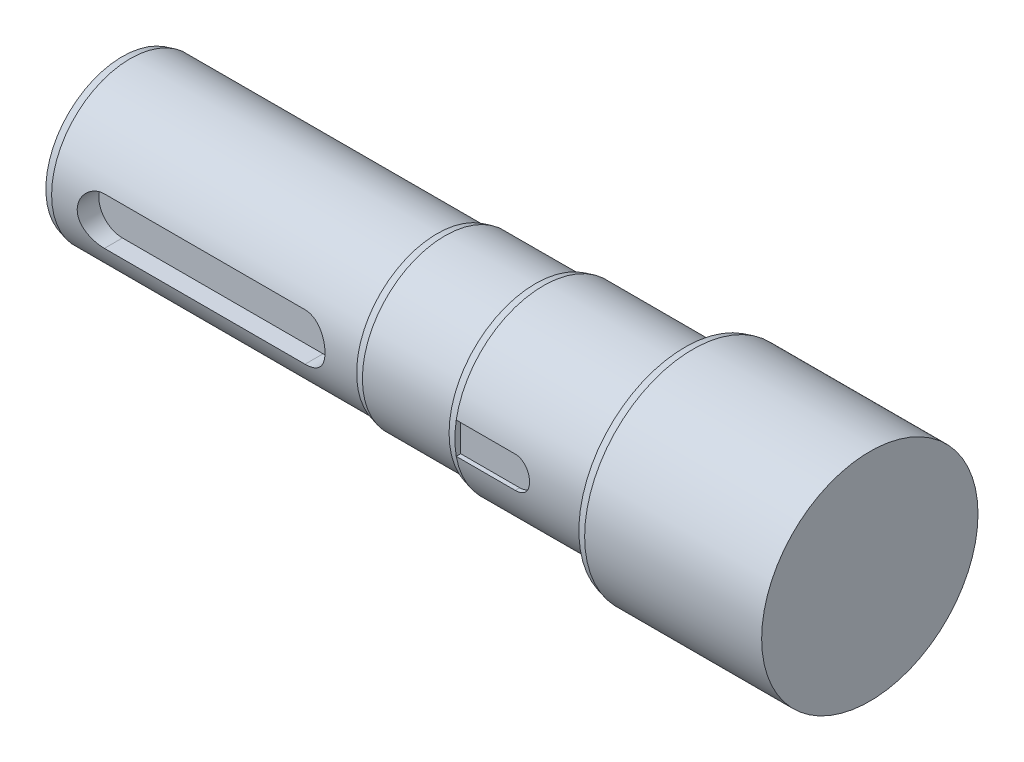
from build123d import *

# Parameters (mm, degrees)
FASE1_SIZE                      = 2
FASE1_SIZE2                     = 0.535898385
FASE1_PART_2_SIZE               = 2
FASE1_PART_2_SIZE2              = 0.535898385
FASE1_PART_3_SIZE               = 2
FASE1_PART_3_SIZE2              = 0.535898385
SCHNITT_LINEAR_AUSTRAGEN1_DEPTH = 5.5
M8_GEWINDEBOHRUNG1_D            = 6.8
M8_GEWINDEBOHRUNG1_DEPTH        = 20
M8_GEWINDEBOHRUNG1_TIP          = 2.042926105
FASE2_SIZE                      = 2
FASE2_SIZE2                     = 0.535898385
SCHNITT_LINEAR_AUSTRAGEN2_DEPTH = 1.5


with BuildPart() as part:
    # Skizze1 → Rotation1 (revolve)
    with BuildSketch(Plane.XY, mode=Mode.PRIVATE) as rotation1_sk:
        Polygon((-85, 22.5), (-70, 22.5), (-47, 22.5), (-47, 27.5), (0, 27.5), (0, 0), (-190, 0), (-190, 20), (-110, 20), (-110, 21), (-85, 21), align=None)
    revolve(rotation1_sk.sketch.rotate(Axis((-55.076928245, 0, 0), (1, 0, 0)), 90), axis=Axis((-55.076928245, 0, 0), (1, 0, 0)))  # turned: the seam where the file's is

    # Fase1
    fase1_edges = [part.edges().sort_by_distance(p)[0] for p in [
        (-47, 0, -27.5),
    ]]
    fase1_side = [part.faces().sort_by_distance(p)[0] for p in [
        (-23.5, 0, -27.5),
    ]]
    chamfer(fase1_edges, length=FASE1_SIZE, length2=FASE1_SIZE2, reference=fase1_side[0])

    # Fase1 part 2
    fase1_part_2_edges = [part.edges().sort_by_distance(p)[0] for p in [
        (-85, 0, -22.5),
    ]]
    fase1_part_2_side = [part.faces().sort_by_distance(p)[0] for p in [
        (-66, 0, -22.5),
    ]]
    chamfer(fase1_part_2_edges, length=FASE1_PART_2_SIZE, length2=FASE1_PART_2_SIZE2, reference=fase1_part_2_side[0])

    # Fase1 part 3
    fase1_part_3_edges = [part.edges().sort_by_distance(p)[0] for p in [
        (-110, 0, -21),
    ]]
    fase1_part_3_side = [part.faces().sort_by_distance(p)[0] for p in [
        (-97.5, 0, -21),
    ]]
    chamfer(fase1_part_3_edges, length=FASE1_PART_3_SIZE, length2=FASE1_PART_3_SIZE2, reference=fase1_part_3_side[0])

    # Skizze2 → Schnitt-Linear austragen1 (cut)
    with BuildSketch(Plane.XY.offset(20)):
        with BuildLine():
            Line((-175.5, 6), (-124.5, 6))
            ThreePointArc((-124.5, 6), (-118.5, 0), (-124.5, -6))
            Line((-124.5, -6), (-175.5, -6))
            ThreePointArc((-175.5, -6), (-181.5, 0), (-175.5, 6))
        make_face()
    extrude(amount=-SCHNITT_LINEAR_AUSTRAGEN1_DEPTH, mode=Mode.SUBTRACT)

    # M8 Gewindebohrung1
    with Locations(Plane.ZY.offset(190)):
        with Locations((0, 10), (0, -10)):
            Hole(M8_GEWINDEBOHRUNG1_D / 2, depth=M8_GEWINDEBOHRUNG1_DEPTH)
            with Locations((0, 0, -(M8_GEWINDEBOHRUNG1_DEPTH + M8_GEWINDEBOHRUNG1_TIP / 2))):  # 118° drill point
                Cone(0, M8_GEWINDEBOHRUNG1_D / 2, M8_GEWINDEBOHRUNG1_TIP, mode=Mode.SUBTRACT)

    # Fase2
    fase2_edges = [part.edges().sort_by_distance(p)[0] for p in [
        (-190, 0, -20),
    ]]
    fase2_side = [part.faces().sort_by_distance(p)[0] for p in [
        (-150, 0, -20),
    ]]
    chamfer(fase2_edges, length=FASE2_SIZE, length2=FASE2_SIZE2, reference=fase2_side[0])

    # Skizze8 → Schnitt-Linear austragen2 (cut)
    with BuildSketch(Plane.XY.offset(22.5)):
        with BuildLine():
            Line((-83, 4), (-68, 4))
            ThreePointArc((-68, 4), (-64, 0), (-68, -4))
            Line((-68, -4), (-83, -4))
            Line((-83, -4), (-83, 4))
        make_face()
    extrude(amount=-SCHNITT_LINEAR_AUSTRAGEN2_DEPTH, mode=Mode.SUBTRACT)


solid = part.part
